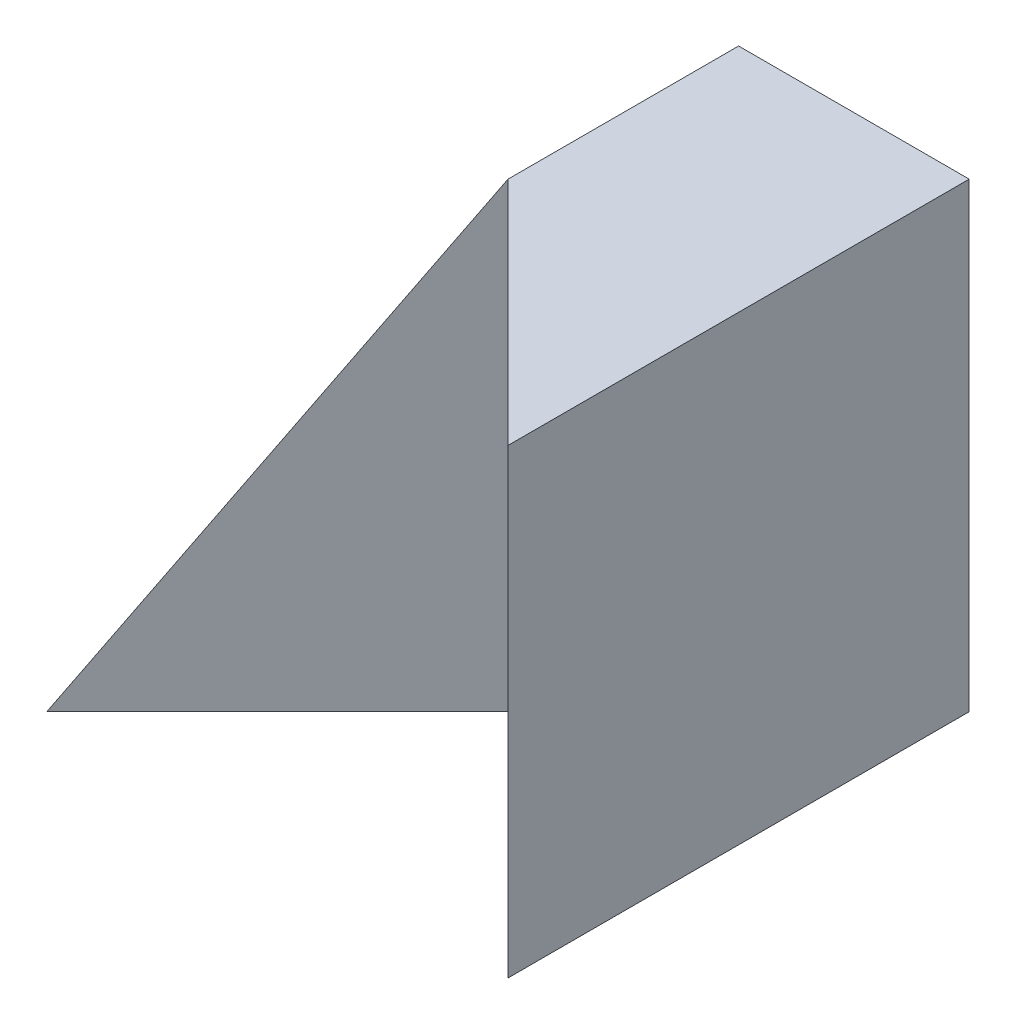
from build123d import *

# Parameters (mm, degrees)
SKETCH1_W           = 40
SKETCH1_H           = 40
BOSS_EXTRUDE1_DEPTH = 40
CUT_EXTRUDE1_DEPTH  = 40
CUT_EXTRUDE2_DEPTH  = 40


with BuildPart() as part:
    # Sketch1 → Boss-Extrude1 (new body)
    with BuildSketch(Plane.XY):
        with Locations((20, 20)):
            Rectangle(SKETCH1_W, SKETCH1_H)
    extrude(amount=BOSS_EXTRUDE1_DEPTH)

    # Sketch2 → Cut-Extrude1 (cut)
    with BuildSketch(Plane.XY.offset(40)):
        Polygon((0, 0), (20, 40), (0, 40), align=None)
    extrude(amount=-CUT_EXTRUDE1_DEPTH, mode=Mode.SUBTRACT)

    # Sketch3 → Cut-Extrude2 (cut)
    with BuildSketch(Plane.XZ):
        Polygon((0, 40), (20, 20), (40, 40), align=None)
    extrude(amount=-CUT_EXTRUDE2_DEPTH, mode=Mode.SUBTRACT)


solid = part.part
